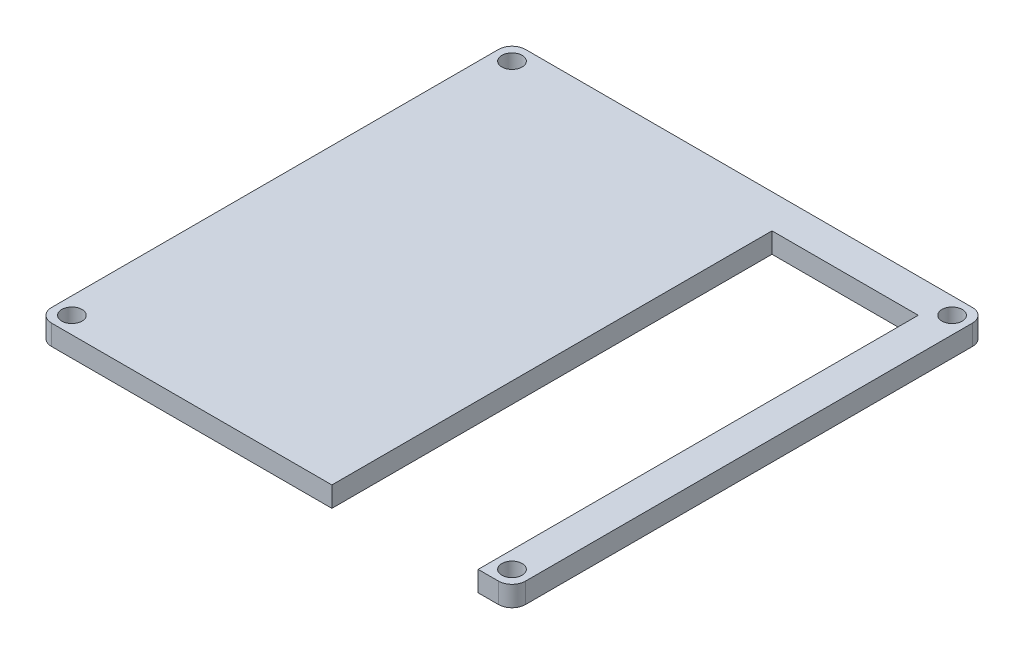
from build123d import *

# Parameters (mm, degrees)
SKETCH1_W           = 70
SKETCH1_H           = 70
SKETCH1_R           = 1.5
BOSS_EXTRUDE1_DEPTH = 3
FILLET1_R           = 2
SKETCH2_W           = 21.6
SKETCH2_H           = 70
CUT_EXTRUDE2_DEPTH  = 10


with BuildPart() as part:
    # Sketch1 → Boss-Extrude1 (new body)
    with BuildSketch(Plane(origin=(0, 0, 0), x_dir=(1, 0, 0), z_dir=(0, 1, 0))):
        Rectangle(SKETCH1_W, SKETCH1_H)
        with Locations((-32.5, 32.5)):
            Circle(SKETCH1_R, mode=Mode.SUBTRACT)
        with Locations((32.5, 32.5)):
            Circle(SKETCH1_R, mode=Mode.SUBTRACT)
        with Locations((32.5, -32.5)):
            Circle(SKETCH1_R, mode=Mode.SUBTRACT)
        with Locations((-32.5, -32.5)):
            Circle(SKETCH1_R, mode=Mode.SUBTRACT)
    extrude(amount=BOSS_EXTRUDE1_DEPTH)

    # Fillet1
    fillet1_edges = [part.edges().sort_by_distance(p)[0] for p in [
        (35, 1.5, 35),
        (-35, 1.5, 35),
        (-35, 1.5, -35),
        (35, 1.5, -35),
    ]]
    fillet(fillet1_edges, radius=FILLET1_R)

    # Sketch2 → Cut-Extrude2 (cut)
    with BuildSketch(Plane(origin=(0, 3, 0), x_dir=(1, 0, 0), z_dir=(0, 1, 0))):
        with Locations((19.2, -5)):
            Rectangle(SKETCH2_W, SKETCH2_H)
    extrude(amount=-CUT_EXTRUDE2_DEPTH, mode=Mode.SUBTRACT)


solid = part.part
